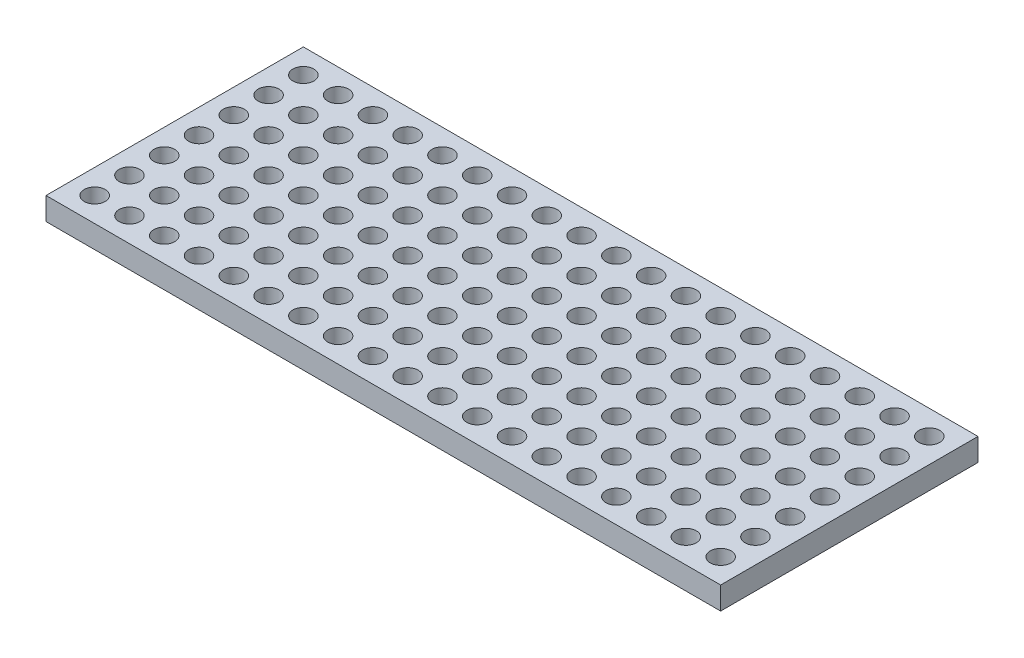
from build123d import *

# Parameters (mm, degrees)
SKETCH1_W           = 97
SKETCH1_H           = 37
SKETCH1_R           = 1.5025
BOSS_EXTRUDE1_DEPTH = 3.25


with BuildPart() as part:
    # Sketch1 → Boss-Extrude1 (new body)
    with BuildSketch(Plane(origin=(0, 0, 0), x_dir=(1, 0, 0), z_dir=(0, 1, 0))):
        Rectangle(SKETCH1_W, SKETCH1_H)
        with Locations((-45, -15)):
            Circle(SKETCH1_R, mode=Mode.SUBTRACT)
        with Locations((-40, -15)):
            Circle(SKETCH1_R, mode=Mode.SUBTRACT)
        with Locations((-35, -15)):
            Circle(SKETCH1_R, mode=Mode.SUBTRACT)
        with Locations((-30, -15)):
            Circle(SKETCH1_R, mode=Mode.SUBTRACT)
        with Locations((-25, -15)):
            Circle(SKETCH1_R, mode=Mode.SUBTRACT)
        with Locations((-20, -15)):
            Circle(SKETCH1_R, mode=Mode.SUBTRACT)
        with Locations((-15, -15)):
            Circle(SKETCH1_R, mode=Mode.SUBTRACT)
        with Locations((-10, -15)):
            Circle(SKETCH1_R, mode=Mode.SUBTRACT)
        with Locations((-5, -15)):
            Circle(SKETCH1_R, mode=Mode.SUBTRACT)
        with Locations((0, -15)):
            Circle(SKETCH1_R, mode=Mode.SUBTRACT)
        with Locations((5, -15)):
            Circle(SKETCH1_R, mode=Mode.SUBTRACT)
        with Locations((10, -15)):
            Circle(SKETCH1_R, mode=Mode.SUBTRACT)
        with Locations((15, -15)):
            Circle(SKETCH1_R, mode=Mode.SUBTRACT)
        with Locations((20, -15)):
            Circle(SKETCH1_R, mode=Mode.SUBTRACT)
        with Locations((25, -15)):
            Circle(SKETCH1_R, mode=Mode.SUBTRACT)
        with Locations((30, -15)):
            Circle(SKETCH1_R, mode=Mode.SUBTRACT)
        with Locations((35, -15)):
            Circle(SKETCH1_R, mode=Mode.SUBTRACT)
        with Locations((40, -15)):
            Circle(SKETCH1_R, mode=Mode.SUBTRACT)
        with Locations((45, -15)):
            Circle(SKETCH1_R, mode=Mode.SUBTRACT)
        with Locations((-40, -10)):
            Circle(SKETCH1_R, mode=Mode.SUBTRACT)
        with Locations((-35, -10)):
            Circle(SKETCH1_R, mode=Mode.SUBTRACT)
        with Locations((-30, -10)):
            Circle(SKETCH1_R, mode=Mode.SUBTRACT)
        with Locations((-25, -10)):
            Circle(SKETCH1_R, mode=Mode.SUBTRACT)
        with Locations((-20, -10)):
            Circle(SKETCH1_R, mode=Mode.SUBTRACT)
        with Locations((-15, -10)):
            Circle(SKETCH1_R, mode=Mode.SUBTRACT)
        with Locations((-10, -10)):
            Circle(SKETCH1_R, mode=Mode.SUBTRACT)
        with Locations((-5, -10)):
            Circle(SKETCH1_R, mode=Mode.SUBTRACT)
        with Locations((0, -10)):
            Circle(SKETCH1_R, mode=Mode.SUBTRACT)
        with Locations((5, -10)):
            Circle(SKETCH1_R, mode=Mode.SUBTRACT)
        with Locations((10, -10)):
            Circle(SKETCH1_R, mode=Mode.SUBTRACT)
        with Locations((15, -10)):
            Circle(SKETCH1_R, mode=Mode.SUBTRACT)
        with Locations((20, -10)):
            Circle(SKETCH1_R, mode=Mode.SUBTRACT)
        with Locations((25, -10)):
            Circle(SKETCH1_R, mode=Mode.SUBTRACT)
        with Locations((30, -10)):
            Circle(SKETCH1_R, mode=Mode.SUBTRACT)
        with Locations((35, -10)):
            Circle(SKETCH1_R, mode=Mode.SUBTRACT)
        with Locations((40, -10)):
            Circle(SKETCH1_R, mode=Mode.SUBTRACT)
        with Locations((45, -10)):
            Circle(SKETCH1_R, mode=Mode.SUBTRACT)
        with Locations((-40, -5)):
            Circle(SKETCH1_R, mode=Mode.SUBTRACT)
        with Locations((-35, -5)):
            Circle(SKETCH1_R, mode=Mode.SUBTRACT)
        with Locations((-30, -5)):
            Circle(SKETCH1_R, mode=Mode.SUBTRACT)
        with Locations((-25, -5)):
            Circle(SKETCH1_R, mode=Mode.SUBTRACT)
        with Locations((-20, -5)):
            Circle(SKETCH1_R, mode=Mode.SUBTRACT)
        with Locations((-15, -5)):
            Circle(SKETCH1_R, mode=Mode.SUBTRACT)
        with Locations((-10, -5)):
            Circle(SKETCH1_R, mode=Mode.SUBTRACT)
        with Locations((-5, -5)):
            Circle(SKETCH1_R, mode=Mode.SUBTRACT)
        with Locations((0, -5)):
            Circle(SKETCH1_R, mode=Mode.SUBTRACT)
        with Locations((5, -5)):
            Circle(SKETCH1_R, mode=Mode.SUBTRACT)
        with Locations((10, -5)):
            Circle(SKETCH1_R, mode=Mode.SUBTRACT)
        with Locations((15, -5)):
            Circle(SKETCH1_R, mode=Mode.SUBTRACT)
        with Locations((20, -5)):
            Circle(SKETCH1_R, mode=Mode.SUBTRACT)
        with Locations((25, -5)):
            Circle(SKETCH1_R, mode=Mode.SUBTRACT)
        with Locations((30, -5)):
            Circle(SKETCH1_R, mode=Mode.SUBTRACT)
        with Locations((35, -5)):
            Circle(SKETCH1_R, mode=Mode.SUBTRACT)
        with Locations((40, -5)):
            Circle(SKETCH1_R, mode=Mode.SUBTRACT)
        with Locations((45, -5)):
            Circle(SKETCH1_R, mode=Mode.SUBTRACT)
        with Locations((-40, 0)):
            Circle(SKETCH1_R, mode=Mode.SUBTRACT)
        with Locations((-35, 0)):
            Circle(SKETCH1_R, mode=Mode.SUBTRACT)
        with Locations((-30, 0)):
            Circle(SKETCH1_R, mode=Mode.SUBTRACT)
        with Locations((-25, 0)):
            Circle(SKETCH1_R, mode=Mode.SUBTRACT)
        with Locations((-20, 0)):
            Circle(SKETCH1_R, mode=Mode.SUBTRACT)
        with Locations((-15, 0)):
            Circle(SKETCH1_R, mode=Mode.SUBTRACT)
        with Locations((-10, 0)):
            Circle(SKETCH1_R, mode=Mode.SUBTRACT)
        with Locations((-5, 0)):
            Circle(SKETCH1_R, mode=Mode.SUBTRACT)
        Circle(SKETCH1_R, mode=Mode.SUBTRACT)
        with Locations((5, 0)):
            Circle(SKETCH1_R, mode=Mode.SUBTRACT)
        with Locations((10, 0)):
            Circle(SKETCH1_R, mode=Mode.SUBTRACT)
        with Locations((15, 0)):
            Circle(SKETCH1_R, mode=Mode.SUBTRACT)
        with Locations((20, 0)):
            Circle(SKETCH1_R, mode=Mode.SUBTRACT)
        with Locations((25, 0)):
            Circle(SKETCH1_R, mode=Mode.SUBTRACT)
        with Locations((30, 0)):
            Circle(SKETCH1_R, mode=Mode.SUBTRACT)
        with Locations((35, 0)):
            Circle(SKETCH1_R, mode=Mode.SUBTRACT)
        with Locations((40, 0)):
            Circle(SKETCH1_R, mode=Mode.SUBTRACT)
        with Locations((45, 0)):
            Circle(SKETCH1_R, mode=Mode.SUBTRACT)
        with Locations((-40, 5)):
            Circle(SKETCH1_R, mode=Mode.SUBTRACT)
        with Locations((-35, 5)):
            Circle(SKETCH1_R, mode=Mode.SUBTRACT)
        with Locations((-30, 5)):
            Circle(SKETCH1_R, mode=Mode.SUBTRACT)
        with Locations((-25, 5)):
            Circle(SKETCH1_R, mode=Mode.SUBTRACT)
        with Locations((-20, 5)):
            Circle(SKETCH1_R, mode=Mode.SUBTRACT)
        with Locations((-15, 5)):
            Circle(SKETCH1_R, mode=Mode.SUBTRACT)
        with Locations((-10, 5)):
            Circle(SKETCH1_R, mode=Mode.SUBTRACT)
        with Locations((-5, 5)):
            Circle(SKETCH1_R, mode=Mode.SUBTRACT)
        with Locations((0, 5)):
            Circle(SKETCH1_R, mode=Mode.SUBTRACT)
        with Locations((5, 5)):
            Circle(SKETCH1_R, mode=Mode.SUBTRACT)
        with Locations((10, 5)):
            Circle(SKETCH1_R, mode=Mode.SUBTRACT)
        with Locations((15, 5)):
            Circle(SKETCH1_R, mode=Mode.SUBTRACT)
        with Locations((20, 5)):
            Circle(SKETCH1_R, mode=Mode.SUBTRACT)
        with Locations((25, 5)):
            Circle(SKETCH1_R, mode=Mode.SUBTRACT)
        with Locations((30, 5)):
            Circle(SKETCH1_R, mode=Mode.SUBTRACT)
        with Locations((35, 5)):
            Circle(SKETCH1_R, mode=Mode.SUBTRACT)
        with Locations((40, 5)):
            Circle(SKETCH1_R, mode=Mode.SUBTRACT)
        with Locations((45, 5)):
            Circle(SKETCH1_R, mode=Mode.SUBTRACT)
        with Locations((-40, 10)):
            Circle(SKETCH1_R, mode=Mode.SUBTRACT)
        with Locations((-35, 10)):
            Circle(SKETCH1_R, mode=Mode.SUBTRACT)
        with Locations((-30, 10)):
            Circle(SKETCH1_R, mode=Mode.SUBTRACT)
        with Locations((-25, 10)):
            Circle(SKETCH1_R, mode=Mode.SUBTRACT)
        with Locations((-20, 10)):
            Circle(SKETCH1_R, mode=Mode.SUBTRACT)
        with Locations((-15, 10)):
            Circle(SKETCH1_R, mode=Mode.SUBTRACT)
        with Locations((-10, 10)):
            Circle(SKETCH1_R, mode=Mode.SUBTRACT)
        with Locations((-5, 10)):
            Circle(SKETCH1_R, mode=Mode.SUBTRACT)
        with Locations((0, 10)):
            Circle(SKETCH1_R, mode=Mode.SUBTRACT)
        with Locations((5, 10)):
            Circle(SKETCH1_R, mode=Mode.SUBTRACT)
        with Locations((10, 10)):
            Circle(SKETCH1_R, mode=Mode.SUBTRACT)
        with Locations((15, 10)):
            Circle(SKETCH1_R, mode=Mode.SUBTRACT)
        with Locations((20, 10)):
            Circle(SKETCH1_R, mode=Mode.SUBTRACT)
        with Locations((25, 10)):
            Circle(SKETCH1_R, mode=Mode.SUBTRACT)
        with Locations((30, 10)):
            Circle(SKETCH1_R, mode=Mode.SUBTRACT)
        with Locations((35, 10)):
            Circle(SKETCH1_R, mode=Mode.SUBTRACT)
        with Locations((40, 10)):
            Circle(SKETCH1_R, mode=Mode.SUBTRACT)
        with Locations((45, 10)):
            Circle(SKETCH1_R, mode=Mode.SUBTRACT)
        with Locations((-40, 15)):
            Circle(SKETCH1_R, mode=Mode.SUBTRACT)
        with Locations((-35, 15)):
            Circle(SKETCH1_R, mode=Mode.SUBTRACT)
        with Locations((-30, 15)):
            Circle(SKETCH1_R, mode=Mode.SUBTRACT)
        with Locations((-25, 15)):
            Circle(SKETCH1_R, mode=Mode.SUBTRACT)
        with Locations((-20, 15)):
            Circle(SKETCH1_R, mode=Mode.SUBTRACT)
        with Locations((-15, 15)):
            Circle(SKETCH1_R, mode=Mode.SUBTRACT)
        with Locations((-10, 15)):
            Circle(SKETCH1_R, mode=Mode.SUBTRACT)
        with Locations((-5, 15)):
            Circle(SKETCH1_R, mode=Mode.SUBTRACT)
        with Locations((0, 15)):
            Circle(SKETCH1_R, mode=Mode.SUBTRACT)
        with Locations((5, 15)):
            Circle(SKETCH1_R, mode=Mode.SUBTRACT)
        with Locations((10, 15)):
            Circle(SKETCH1_R, mode=Mode.SUBTRACT)
        with Locations((15, 15)):
            Circle(SKETCH1_R, mode=Mode.SUBTRACT)
        with Locations((20, 15)):
            Circle(SKETCH1_R, mode=Mode.SUBTRACT)
        with Locations((25, 15)):
            Circle(SKETCH1_R, mode=Mode.SUBTRACT)
        with Locations((30, 15)):
            Circle(SKETCH1_R, mode=Mode.SUBTRACT)
        with Locations((35, 15)):
            Circle(SKETCH1_R, mode=Mode.SUBTRACT)
        with Locations((40, 15)):
            Circle(SKETCH1_R, mode=Mode.SUBTRACT)
        with Locations((45, 15)):
            Circle(SKETCH1_R, mode=Mode.SUBTRACT)
        with Locations((-45, -10)):
            Circle(SKETCH1_R, mode=Mode.SUBTRACT)
        with Locations((-45, -5)):
            Circle(SKETCH1_R, mode=Mode.SUBTRACT)
        with Locations((-45, 0)):
            Circle(SKETCH1_R, mode=Mode.SUBTRACT)
        with Locations((-45, 5)):
            Circle(SKETCH1_R, mode=Mode.SUBTRACT)
        with Locations((-45, 10)):
            Circle(SKETCH1_R, mode=Mode.SUBTRACT)
        with Locations((-45, 15)):
            Circle(SKETCH1_R, mode=Mode.SUBTRACT)
    extrude(amount=BOSS_EXTRUDE1_DEPTH)


solid = part.part
